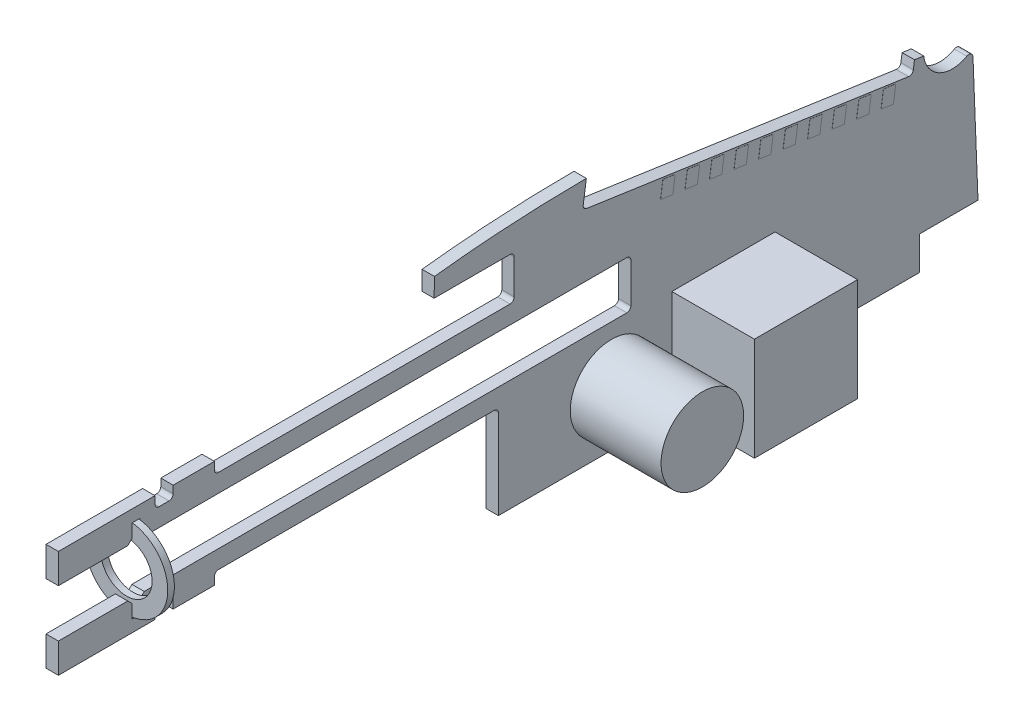
from build123d import *

# Parameters (mm, degrees)
BOSS_EXTRUDE1_DEPTH      = 0.75
BOSS_EXTRUDE1_DEPTH_BACK = 0.75
BOSS_EXTRUDE2_START      = -1.9
SKETCH3_R                = 5
SKETCH3_R_2              = 3.1
BOSS_EXTRUDE2_DEPTH      = 0.8
BOSS_EXTRUDE3_DEPTH      = 0.01
SKETCH7_W                = 12.494603103
SKETCH7_H                = 12.494603103
BOSS_EXTRUDE4_DEPTH      = 10
SKETCH8_R                = 5
BOSS_EXTRUDE5_DEPTH      = 11


with BuildPart() as part:
    # Sketch1 → Boss-Extrude1 (new, two sides: drawn at the far end of the back side and taken through both)
    with BuildSketch(Plane(origin=(0, 0, 0), x_dir=(0, 0, -1), z_dir=(1, 0, 0)).offset(-BOSS_EXTRUDE1_DEPTH_BACK)):
        with BuildLine():
            Line((37.45, -2.436931654), (37.45, 2.363068346))
            ThreePointArc((37.45, 2.363068346), (37.303553391, 2.716621736), (36.95, 2.863068346))
            Line((36.95, 2.863068346), (-21.5, 2.863068346))
            Line((-21.5, 2.863068346), (-22, 3.363068346))
            Line((-22, 3.363068346), (-22, 4.993594932))
            Line((-22, 4.993594932), (-23, 4.993594932))
            Line((-23, 4.993594932), (-23, 3.363068346))
            Line((-23, 3.363068346), (-23.5, 2.863068346))
            Line((-23.5, 2.863068346), (-31.90354955, 2.863068346))
            Line((-31.90354955, 2.863068346), (-31.90354955, 6.463068346))
            Line((-31.90354955, 6.463068346), (-20.2, 6.463068346))
            Line((-20.2, 6.463068346), (-20.2, 5.563068346))
            ThreePointArc((-20.2, 5.563068346), (-20.053553391, 5.209514955), (-19.7, 5.063068346))
            Line((-19.7, 5.063068346), (-18.5, 5.063068346))
            ThreePointArc((-18.5, 5.063068346), (-18.146446609, 5.209514955), (-18, 5.563068346))
            Line((-18, 5.563068346), (-18, 6.463068346))
            Line((-18, 6.463068346), (-13, 6.463068346))
            Line((-13, 6.463068346), (-13, 5.563068346))
            ThreePointArc((-13, 5.563068346), (-12.853553391, 5.209514955), (-12.5, 5.063068346))
            Line((-12.5, 5.063068346), (22.808726868, 5.063068346))
            ThreePointArc((22.808726868, 5.063068346), (23.162280258, 5.209514955), (23.308726868, 5.563068346))
            Line((23.308726868, 5.563068346), (23.308726868, 9.763832191))
            ThreePointArc((23.308726868, 9.763832191), (23.162280258, 10.117385581), (22.808726868, 10.263832191))
            Line((22.808726868, 10.263832191), (13.613096845, 10.263832191))
            Line((13.613096845, 10.263832191), (13.652735343, 12.534720206))
            add(Edge.make_bspline(
                [(32.054900348, 13.621703513), (30.632810596, 13.618897937), (27.64469846, 13.573512435), (23.109018983, 13.37869396), (18.397561725, 13.039599309), (15.246931074, 12.72008221), (13.652735343, 12.534720206)],
                knots=[0.843998206, 0.843998206, 0.843998206, 0.843998206, 0.921319408, 1.006376572, 1.091433737, 1.178910534, 1.178910534, 1.178910534, 1.178910534], degree=3))
            Line((32.054900348, 13.621703513), (31.675937422, 11.012861513))
            ThreePointArc((31.675937422, 11.012861513), (31.770038899, 10.641928201), (32.098868151, 10.446178534))
            Line((32.098868151, 10.446178534), (71.089648239, 4.782339895))
            ThreePointArc((71.089648239, 4.782339895), (71.46058155, 4.876441372), (71.656331218, 5.205270624))
            Line((71.656331218, 5.205270624), (71.800083467, 6.194884332))
            Line((71.800083467, 6.194884332), (72.922346789, 6.031863269))
            ThreePointArc((72.922346789, 6.031863269), (74.822358128, 3.309709233), (78.140832287, 3.398562734))
            ThreePointArc((78.140832287, 3.398562734), (78.6316623, 3.402395008), (78.889259875, 2.984576534))
            Line((78.889259875, 2.984576534), (79.495780173, -12.391250274))
            Line((79.495780173, -12.391250274), (72.383118526, -12.391250274))
            Line((72.383118526, -12.391250274), (72.383118526, -16.433593955))
            Line((72.383118526, -16.433593955), (63.19645045, -16.433593955))
            Line((63.19645045, -16.433593955), (63.19645045, -15.833593955))
            ThreePointArc((63.19645045, -15.833593955), (59.69645045, -12.333593955), (56.19645045, -15.833593955))
            Line((56.19645045, -15.833593955), (56.19645045, -16.433593955))
            Line((56.19645045, -16.433593955), (21.39645045, -16.433593955))
            Line((21.39645045, -16.433593955), (21.39645045, -5.636931654))
            ThreePointArc((21.39645045, -5.636931654), (21.25000384, -5.283378264), (20.89645045, -5.136931654))
            Line((20.89645045, -5.136931654), (-12.5, -5.136931654))
            ThreePointArc((-12.5, -5.136931654), (-12.853553391, -5.283378264), (-13, -5.636931654))
            Line((-13, -5.636931654), (-13, -6.536931654))
            Line((-13, -6.536931654), (-18, -6.536931654))
            Line((-18, -6.536931654), (-18, -5.636931654))
            ThreePointArc((-18, -5.636931654), (-18.146446609, -5.283378264), (-18.5, -5.136931654))
            Line((-18.5, -5.136931654), (-19.7, -5.136931654))
            ThreePointArc((-19.7, -5.136931654), (-20.05355339, -5.283378264), (-20.2, -5.636931654))
            Line((-20.2, -5.636931654), (-20.2, -6.536931654))
            Line((-20.2, -6.536931654), (-31.90354955, -6.536931654))
            Line((-31.90354955, -6.536931654), (-31.90354955, -2.936931654))
            Line((-31.90354955, -2.936931654), (-23.5, -2.936931654))
            Line((-23.5, -2.936931654), (-23, -3.436931654))
            Line((-23, -3.436931654), (-23, -5.093265035))
            Line((-23, -5.093265035), (-22, -5.093265035))
            Line((-22, -5.093265035), (-22, -3.436931654))
            Line((-22, -3.436931654), (-21.5, -2.936931654))
            Line((-21.5, -2.936931654), (36.95, -2.936931654))
            ThreePointArc((36.95, -2.936931654), (37.303553391, -2.790485045), (37.45, -2.436931654))
        make_face()
    extrude(amount=BOSS_EXTRUDE1_DEPTH + BOSS_EXTRUDE1_DEPTH_BACK)

    # Sketch6 → Boss-Extrude3 (add)
    with BuildSketch(Plane(origin=(0.75, 0, 0), x_dir=(0, 0, -1), z_dir=(1, 0, 0))):
        Polygon((48.74107838, 7.815821162), (48.45357388, 5.836593747), (46.969153318, 6.052222121), (47.256657818, 8.031449537), align=None)
        Polygon((42.515891633, 6.699107245), (41.031471072, 6.914735619), (41.318975571, 8.893963035), (42.803396133, 8.67833466), align=None)
        Polygon((45.484732757, 6.267850496), (44.000312195, 6.48347887), (44.287816694, 8.462706286), (45.772237256, 8.247077911), align=None)
        Polygon((66.266620621, 3.249053252), (64.782200059, 3.464681626), (65.069704559, 5.443909042), (66.55412512, 5.228280667), align=None)
        Polygon((69.235461744, 2.817796503), (67.751041183, 3.033424877), (68.038545682, 5.012652293), (69.522966244, 4.797023918), align=None)
        Polygon((50.225498941, 7.600192788), (49.937994442, 5.620965372), (51.422415004, 5.405336997), (51.709919503, 7.384564413), align=None)
        Polygon((53.194340065, 7.168936038), (52.906835565, 5.189708623), (54.391256127, 4.974080248), (54.678760627, 6.953307664), align=None)
        Polygon((56.163181188, 6.737679289), (55.875676689, 4.758451874), (57.360097251, 4.542823499), (57.64760175, 6.522050915), align=None)
        Polygon((59.132022312, 6.30642254), (58.844517812, 4.327195125), (60.328938374, 4.11156675), (60.616442873, 6.090794166), align=None)
        Polygon((62.100863435, 5.875165791), (61.813358936, 3.895938375), (63.297779497, 3.680310001), (63.585283997, 5.659537416), align=None)
    extrude(amount=BOSS_EXTRUDE3_DEPTH)

    # Sketch7 → Boss-Extrude4 (add)
    with BuildSketch(Plane(origin=(0.75, 0, 0), x_dir=(0, 0, -1), z_dir=(1, 0, 0))):
        with Locations((48.660372479, -9.672279041)):
            Rectangle(SKETCH7_W, SKETCH7_H)
    extrude(amount=BOSS_EXTRUDE4_DEPTH)

    # Sketch8 → Boss-Extrude5 (add)
    with BuildSketch(Plane(origin=(0.75, 0, 0), x_dir=(0, 0, -1), z_dir=(1, 0, 0))):
        with Locations((35.103510038, -9.786647509)):
            Circle(SKETCH8_R)
    extrude(amount=BOSS_EXTRUDE5_DEPTH)


with BuildPart() as body_2:
    # Sketch3 → Boss-Extrude2 (new body)
    with BuildSketch(Plane(origin=(0, 0, 20.2), x_dir=(-1, 0, 0), z_dir=(0, 0, -1)).offset(BOSS_EXTRUDE2_START)):
        Circle(SKETCH3_R)
        Circle(SKETCH3_R_2, mode=Mode.SUBTRACT)
    extrude(amount=-BOSS_EXTRUDE2_DEPTH)


solid = Compound([part.part, body_2.part])
